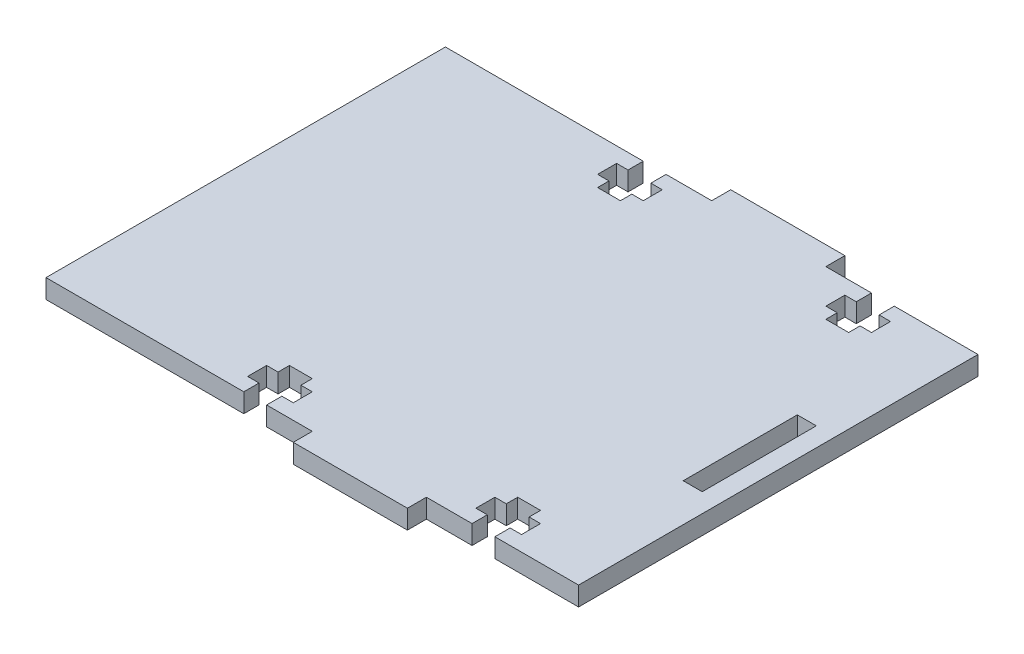
from build123d import *

# Parameters (mm, degrees)
SKETCH1_W           = 3.175
SKETCH1_H           = 19.05
BOSS_EXTRUDE3_DEPTH = 3.175


with BuildPart() as part:
    # Sketch1 → Boss-Extrude3 (new body)
    with BuildSketch(Plane(origin=(0, 0, 0), x_dir=(1, 0, 0), z_dir=(0, 1, 0))):
        Polygon((0, 66.675), (0, 0), (33.02, 0), (33.02, 2.54), (31.115, 2.54), (31.115, 5.715), (33.02, 5.715), (33.02, 7.62), (36.83, 7.62), (36.83, 5.715), (38.735, 5.715), (38.735, 2.54), (36.83, 2.54), (36.83, 0), (44.45, 0), (44.45, -3.175), (63.5, -3.175), (63.5, 0), (71.12, 0), (71.12, 2.54), (69.215, 2.54), (69.215, 5.715), (71.12, 5.715), (71.12, 7.62), (74.93, 7.62), (74.93, 5.715), (76.835, 5.715), (76.835, 2.54), (74.93, 2.54), (74.93, 0), (88.9, 0), (88.9, 66.675), (74.93, 66.675), (74.93, 64.135), (76.835, 64.135), (76.835, 60.96), (74.93, 60.96), (74.93, 59.055), (71.12, 59.055), (71.12, 60.96), (69.215, 60.96), (69.215, 64.135), (71.12, 64.135), (71.12, 66.675), (63.5, 66.675), (63.5, 69.85), (44.45, 69.85), (44.45, 66.675), (36.83, 66.675), (36.83, 64.135), (38.735, 64.135), (38.735, 60.96), (36.83, 60.96), (36.83, 59.055), (33.02, 59.055), (33.02, 60.96), (31.115, 60.96), (31.115, 64.135), (33.02, 64.135), (33.02, 66.675), align=None)
        with Locations((84.1375, 33.3375)):
            Rectangle(SKETCH1_W, SKETCH1_H, mode=Mode.SUBTRACT)
    extrude(amount=BOSS_EXTRUDE3_DEPTH)


solid = part.part
